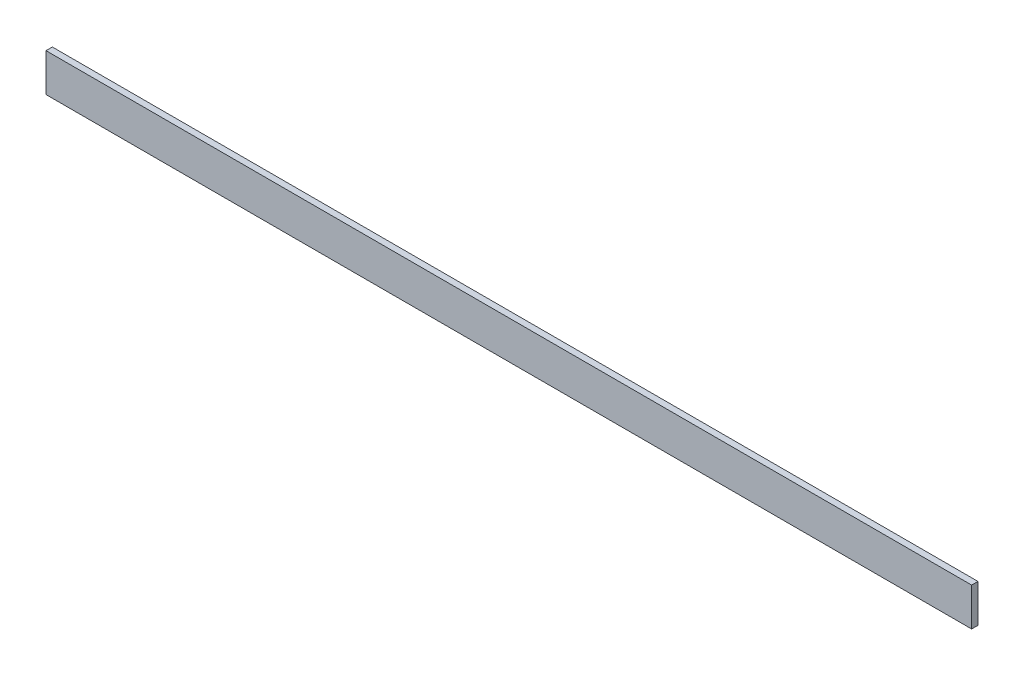
from build123d import *

# Parameters (mm, degrees)
SKETCH_1_W      = 5
SKETCH_1_H      = 30
EXTRUDE_1_DEPTH = 730


with BuildPart() as part:
    # Эскиз1 → Бобышка-Вытянуть1 (new body)
    with BuildSketch(Plane(origin=(0, 0, 0), x_dir=(0, 0, -1), z_dir=(1, 0, 0))):
        with Locations((2.5, 15)):
            Rectangle(SKETCH_1_W, SKETCH_1_H)
    extrude(amount=EXTRUDE_1_DEPTH)


solid = part.part
